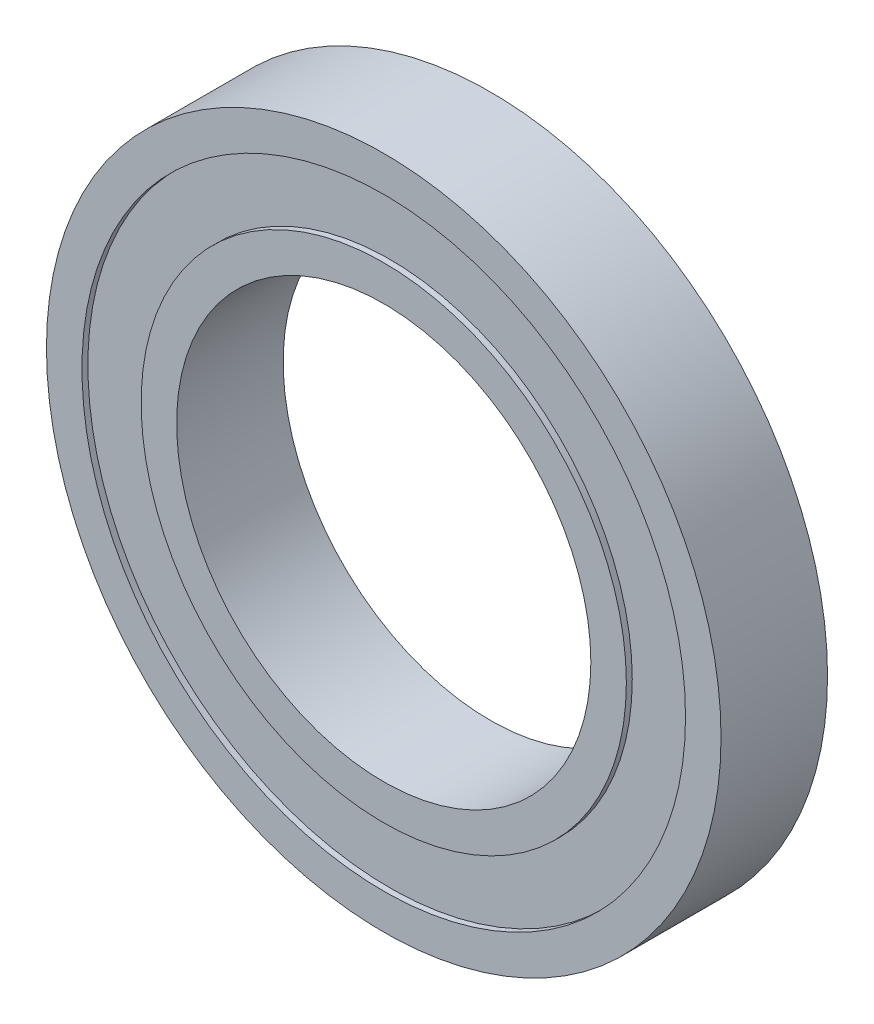
from build123d import *

# Parameters (mm, degrees)
SKETCH1_R             = 28.5
SKETCH1_R_2           = 25.5
BOSS_EXTRUDE1_DEPTH   = 9
SKETCH1_R_3           = 20.5
SKETCH1_R_4           = 17.5
BOSS_EXTRUDE1_2_DEPTH = 9
BOSS_EXTRUDE2_START   = 0.5
SKETCH1_3_R           = 25.5
SKETCH1_3_R_2         = 20.5
BOSS_EXTRUDE2_DEPTH   = 8


with BuildPart() as part:
    # Sketch1 → Boss-Extrude1 (new body)
    with BuildSketch(Plane(origin=(0, 0, 0), x_dir=(0, 1, 0), z_dir=(0, 0, 1))):
        Circle(SKETCH1_R)
        Circle(SKETCH1_R_2, mode=Mode.SUBTRACT)
    extrude(amount=BOSS_EXTRUDE1_DEPTH)



with BuildPart() as body_2:
    # Sketch1 → Boss-Extrude1 2 (new body)
    with BuildSketch(Plane(origin=(0, 0, 0), x_dir=(0, 1, 0), z_dir=(0, 0, 1))):
        Circle(SKETCH1_R_3)
        Circle(SKETCH1_R_4, mode=Mode.SUBTRACT)
    extrude(amount=BOSS_EXTRUDE1_2_DEPTH)


with BuildPart() as part_1:
    add(part.part)

    add(body_2.part)  # Boss-Extrude2 merges body 2
    # Sketch1_3 → Boss-Extrude2 (add)
    with BuildSketch(Plane(origin=(0, 0, 0), x_dir=(0, 1, 0), z_dir=(0, 0, 1)).offset(BOSS_EXTRUDE2_START)):
        Circle(SKETCH1_3_R)
        Circle(SKETCH1_3_R_2, mode=Mode.SUBTRACT)
    extrude(amount=BOSS_EXTRUDE2_DEPTH)


solid = part_1.part
